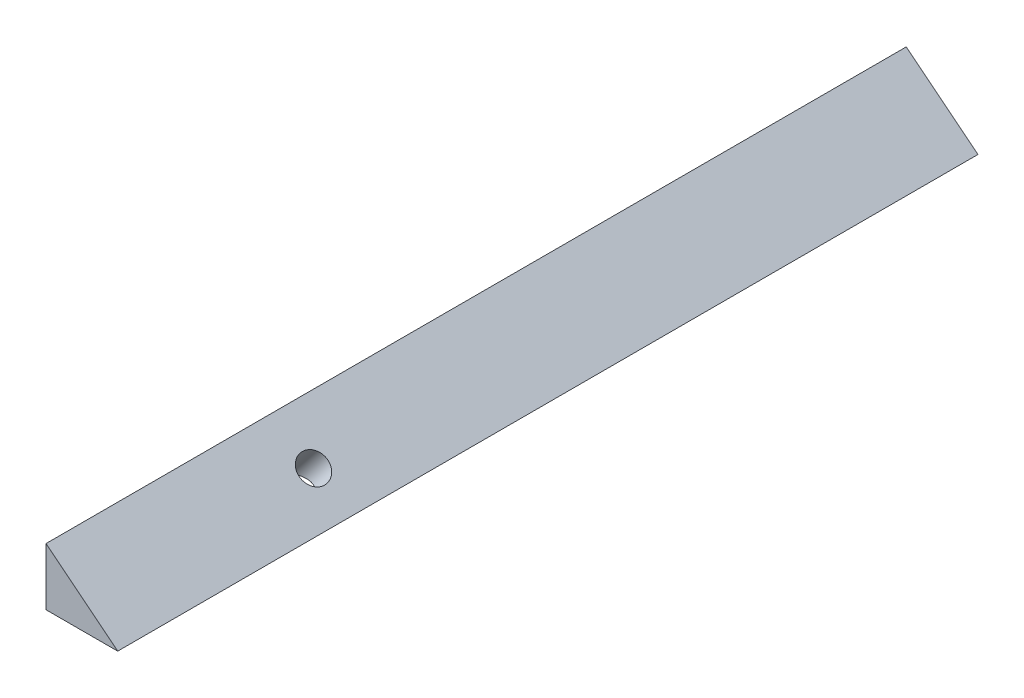
from build123d import *

# Parameters (mm, degrees)
BOSS_EXTRUDE1_DEPTH = 38.1
BOSS_EXTRUDE2_DEPTH = 292.1
BOSS_EXTRUDE3_DEPTH = 431.8
SKETCH6_R           = 12.7
CUT_EXTRUDE2_DEPTH  = 431.8


with BuildPart() as part:
    # Sketch1 → Boss-Extrude1 (new body)
    with BuildSketch(Plane.XY):
        Polygon((0, 0), (0, 50.8), (63.5, 0), align=None)
    extrude(amount=-BOSS_EXTRUDE1_DEPTH)

    # Sketch3 → Boss-Extrude2 (add)
    with BuildSketch(Plane.XY):
        Polygon((0, 50.8), (0, 0), (63.5, 0), align=None)
    extrude(amount=BOSS_EXTRUDE2_DEPTH)

    # Sketch4 → Boss-Extrude3 (add)
    with BuildSketch(Plane(origin=(0, 0, -38.1), x_dir=(-1, 0, 0), z_dir=(0, 0, -1))):
        Polygon((0, 50.8), (-63.5, 0), (0, 0), align=None)
    extrude(amount=BOSS_EXTRUDE3_DEPTH)

    # Sketch6 → Cut-Extrude2 (cut)
    with BuildSketch(Plane(origin=(24.780487805, 30.975609756, 0), x_dir=(0.780868809, -0.624695048, 0), z_dir=(0.624695048, 0.780868809, 0))):
        with Locations((11.4851694, -88.9)):
            Circle(SKETCH6_R)
    extrude(amount=-CUT_EXTRUDE2_DEPTH, mode=Mode.SUBTRACT)


solid = part.part
